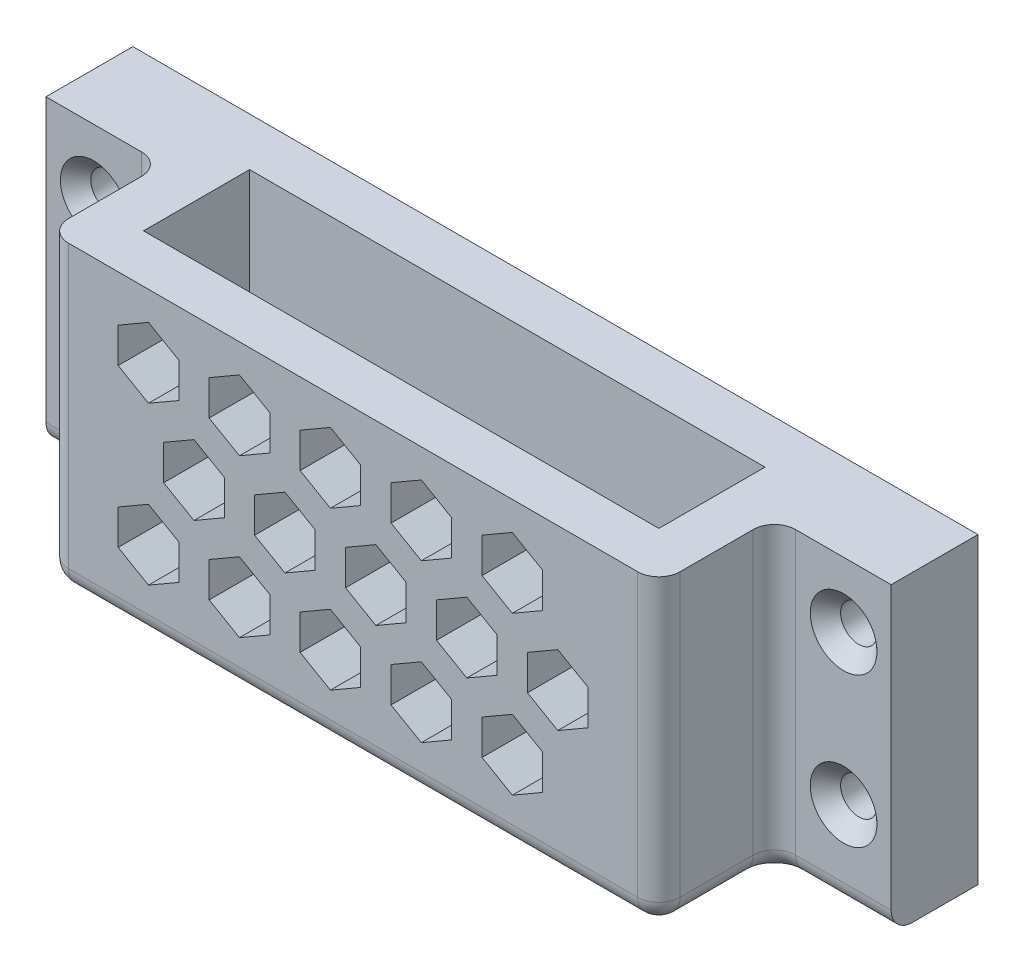
from build123d import *

# Parameters (mm, degrees)
SKETCH4_W                                       = 40.35
SKETCH4_H                                       = 13.35
BOSS_EXTRUDE3_DEPTH                             = 20
SHELL2_T                                        = -3.175
FILLET3_R                                       = 1.4
FILLET4_R                                       = 1.4
SKETCH5_W                                       = 5.73
SKETCH5_H                                       = 20
BOSS_EXTRUDE4_DEPTH                             = 7.702
FILLET5_R                                       = 1.4
FILLET6_R                                       = 1.4
CUT_EXTRUDE3_DEPTH                              = 3.175
FILLET7_R                                       = 1.4
CSK_FOR_M2_FLAT_HEAD_MACHINE_SCREW1_D           = 2.4
CSK_FOR_M2_FLAT_HEAD_MACHINE_SCREW1_CSINK_D     = 4.4
CSK_FOR_M2_FLAT_HEAD_MACHINE_SCREW1_CSINK_ANGLE = 90


with BuildPart() as part:
    # Sketch4 → Boss-Extrude3 (new body)
    with BuildSketch(Plane(origin=(0, 0, 0), x_dir=(1, 0, 0), z_dir=(0, 1, 0))):
        Rectangle(SKETCH4_W, SKETCH4_H)
    extrude(amount=BOSS_EXTRUDE3_DEPTH)

    # Shell2
    shell2_openings = [part.faces().sort_by_distance(p)[0] for p in [
        (0, 20, 0),
    ]]
    offset(amount=SHELL2_T, openings=shell2_openings, kind=Kind.INTERSECTION)

    # Fillet3
    fillet3_edges = [part.edges().sort_by_distance(p)[0] for p in [
        (20.175, 10, 6.675),
    ]]
    fillet(fillet3_edges, radius=FILLET3_R)

    # Fillet4
    fillet4_edges = [part.edges().sort_by_distance(p)[0] for p in [
        (-20.175, 10, 6.675),
    ]]
    fillet(fillet4_edges, radius=FILLET4_R)

    # Sketch5 → Boss-Extrude4 (add)
    with BuildSketch(Plane(origin=(20.175, 0, 0), x_dir=(0, 0, -1), z_dir=(1, 0, 0))):
        with Locations((3.81, 10)):
            Rectangle(SKETCH5_W, SKETCH5_H)
    boss_extrude4 = extrude(amount=BOSS_EXTRUDE4_DEPTH)

    # Mirror3: Boss-Extrude4 across plane
    add(boss_extrude4.mirror(Plane.ZY))

    # Fillet5
    fillet5_edges = [part.edges().sort_by_distance(p)[0] for p in [
        (-20.175, 10, -0.945),
    ]]
    fillet(fillet5_edges, radius=FILLET5_R)

    # Fillet6
    fillet6_edges = [part.edges().sort_by_distance(p)[0] for p in [
        (20.175, 10, -0.945),
    ]]
    fillet(fillet6_edges, radius=FILLET6_R)

    # Sketch6 → Cut-Extrude3 (cut)
    with BuildSketch(Plane.XY.offset(6.675)):
        Polygon((-10.495, 8.293847577), (-8.495, 9.448548116), (-8.495, 11.757949192), (-10.495, 12.912649731), (-12.495, 11.757949192), (-12.495, 9.448548116), align=None)
        Polygon((-13.495, 13.49), (-11.495, 14.644700538), (-11.495, 16.954101615), (-13.495, 18.108802154), (-15.495, 16.954101615), (-15.495, 14.644700538), align=None)
        Polygon((-4.495, 8.293847577), (-2.495, 9.448548116), (-2.495, 11.757949192), (-4.495, 12.912649731), (-6.495, 11.757949192), (-6.495, 9.448548116), align=None)
        Polygon((-7.495, 13.49), (-5.495, 14.644700538), (-5.495, 16.954101615), (-7.495, 18.108802154), (-9.495, 16.954101615), (-9.495, 14.644700538), align=None)
        Polygon((1.505, 8.293847577), (3.505, 9.448548116), (3.505, 11.757949192), (1.505, 12.912649731), (-0.495, 11.757949192), (-0.495, 9.448548116), align=None)
        Polygon((-1.495, 13.49), (0.505, 14.644700538), (0.505, 16.954101615), (-1.495, 18.108802154), (-3.495, 16.954101615), (-3.495, 14.644700538), align=None)
        Polygon((7.505, 8.293847577), (9.505, 9.448548116), (9.505, 11.757949192), (7.505, 12.912649731), (5.505, 11.757949192), (5.505, 9.448548116), align=None)
        Polygon((4.505, 13.49), (6.505, 14.644700538), (6.505, 16.954101615), (4.505, 18.108802154), (2.505, 16.954101615), (2.505, 14.644700538), align=None)
        Polygon((13.505, 8.293847577), (15.505, 9.448548116), (15.505, 11.757949192), (13.505, 12.912649731), (11.505, 11.757949192), (11.505, 9.448548116), align=None)
        Polygon((10.505, 13.49), (12.505, 14.644700538), (12.505, 16.954101615), (10.505, 18.108802154), (8.505, 16.954101615), (8.505, 14.644700538), align=None)
        Polygon((-7.495, 3.1), (-5.495, 4.254700538), (-5.495, 6.564101615), (-7.495, 7.718802154), (-9.495, 6.564101615), (-9.495, 4.254700538), align=None)
        Polygon((-1.495, 3.1), (0.505, 4.254700538), (0.505, 6.564101615), (-1.495, 7.718802154), (-3.495, 6.564101615), (-3.495, 4.254700538), align=None)
        Polygon((4.505, 3.1), (6.505, 4.254700538), (6.505, 6.564101615), (4.505, 7.718802154), (2.505, 6.564101615), (2.505, 4.254700538), align=None)
        Polygon((10.505, 3.1), (12.505, 4.254700538), (12.505, 6.564101615), (10.505, 7.718802154), (8.505, 6.564101615), (8.505, 4.254700538), align=None)
        Polygon((-13.495, 3.1), (-11.495, 4.254700538), (-11.495, 6.564101615), (-13.495, 7.718802154), (-15.495, 6.564101615), (-15.495, 4.254700538), align=None)
    extrude(amount=-CUT_EXTRUDE3_DEPTH, mode=Mode.SUBTRACT)

    # Fillet7
    fillet7_edges = [part.edges().sort_by_distance(p)[0] for p in [
        (20.175, 0, 2.865),
        (19.764949494, 0, 6.264949494),
        (0, 0, 6.675),
        (-19.764949494, 0, 6.264949494),
        (24.726, 0, -0.945),
        (-24.726, 0, -0.945),
        (-20.175, 0, 2.865),
        (-20.585050506, 0, -0.534949494),
        (20.585050506, 0, -0.534949494),
    ]]
    fillet(fillet7_edges, radius=FILLET7_R)

    # CSK for M2 Flat Head Machine Screw1 (through all)
    with Locations(Plane.XY.offset(-0.945)):
        with Locations((-24.725731378, 15.718875268), (-24.725731378, 5.864523718), (24.743113404, 5.864523718), (24.743113404, 15.718875268)):
            CounterSinkHole(CSK_FOR_M2_FLAT_HEAD_MACHINE_SCREW1_D / 2, CSK_FOR_M2_FLAT_HEAD_MACHINE_SCREW1_CSINK_D / 2, counter_sink_angle=CSK_FOR_M2_FLAT_HEAD_MACHINE_SCREW1_CSINK_ANGLE)


solid = part.part
